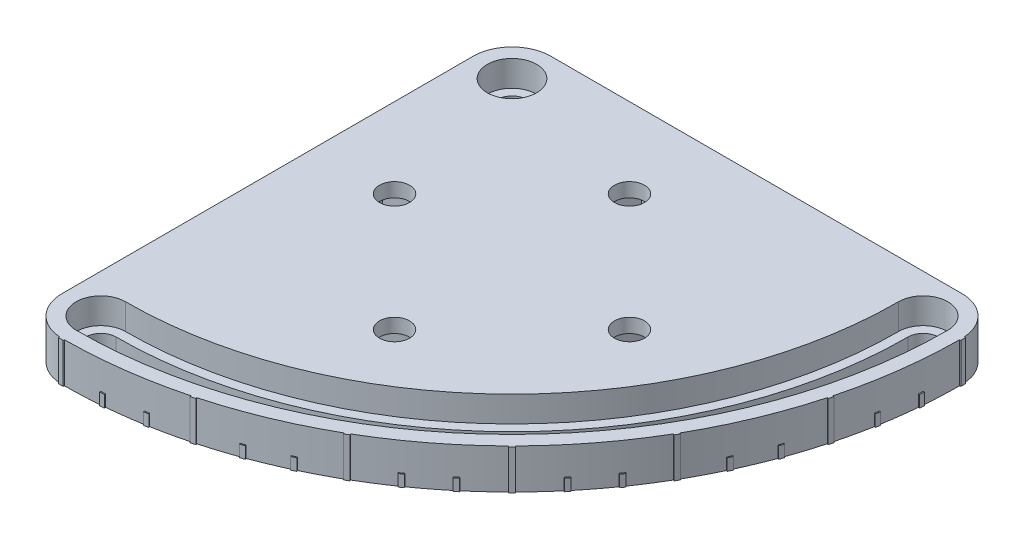
from build123d import *

# Parameters (mm, degrees)
SKETCH_1_R               = 3.2
EXTRUDE_1_DEPTH          = 8.5
EXTRUDE_2_DEPTH          = 8.5
PATTERN_CIRCULAR_1_COUNT = 7
PATTERN_CIRCULAR_1_ANGLE = 90
EXTRUDE_3_DEPTH          = 2.5
PATTERN_CIRCULAR_2_COUNT = 19
PATTERN_CIRCULAR_2_ANGLE = 90
CUT_EXTRUDE_1_DEPTH      = 5.5
CUT_EXTRUDE_2_DEPTH      = 5.5
EXTRUDE_4_DEPTH          = 8.5
SKETCH_10_R              = 3.25
CUT_EXTRUDE_3_DEPTH      = 8.5
SKETCH_11_R              = 5.25
CUT_EXTRUDE_4_DEPTH      = 5.5


with BuildPart() as part:
    # 스케치1 → 보스-돌출1 (new body)
    with BuildSketch(Plane(origin=(0, 0, 0), x_dir=(1, 0, 0), z_dir=(0, 1, 0))):
        with BuildLine():
            Line((-8.25, -87.5), (-8.25, -22.5))
            ThreePointArc((-8.25, -22.5), (-5.833630945, -16.666369055), (0, -14.25))
            ThreePointArc((0, -14.25), (10.076271632, -10.076271632), (14.25, 0))
            ThreePointArc((14.25, 0), (16.666369055, 5.833630945), (22.5, 8.25))
            Line((22.5, 8.25), (87.5, 8.25))
            ThreePointArc((87.5, 8.25), (93.333630945, 5.833630945), (95.75, 0))
            ThreePointArc((95.75, 0), (67.705474299, -67.705474299), (0, -95.75))
            ThreePointArc((0, -95.75), (-5.833630945, -93.333630945), (-8.25, -87.5))
        make_face()
        with Locations((58.75, -33.75)):
            Circle(SKETCH_1_R, mode=Mode.SUBTRACT)
        with Locations((33.75, -58.75)):
            Circle(SKETCH_1_R, mode=Mode.SUBTRACT)
        with Locations((8.75, -33.75)):
            Circle(SKETCH_1_R, mode=Mode.SUBTRACT)
        with Locations((33.75, -8.75)):
            Circle(SKETCH_1_R, mode=Mode.SUBTRACT)
        with BuildLine():
            ThreePointArc((0, -19.25), (-3.25, -22.5), (0, -25.75))
            ThreePointArc((0, -25.75), (18.207999616, -18.207999616), (25.75, 0))
            ThreePointArc((25.75, 0), (22.5, 3.25), (19.25, 0))
            ThreePointArc((19.25, 0), (13.611805538, -13.611805538), (0, -19.25))
        make_face(mode=Mode.SUBTRACT)
        with BuildLine():
            ThreePointArc((0, -84.25), (-3.25, -87.5), (0, -90.75))
            ThreePointArc((0, -90.75), (64.169940393, -64.169940393), (90.75, 0))
            ThreePointArc((90.75, 0), (87.5, 3.25), (84.25, 0))
            ThreePointArc((84.25, 0), (59.573746315, -59.573746315), (0, -84.25))
        make_face(mode=Mode.SUBTRACT)
    extrude(amount=EXTRUDE_1_DEPTH)

    # 스케치2 → 보스-돌출2 (add)
    with BuildSketch(Plane(origin=(0, 8.5, 0), x_dir=(1, 0, 0), z_dir=(0, 1, 0))):
        with BuildLine():
            Line((0.497416564, -94.998697764), (0.502652528, -95.998684056))
            ThreePointArc((0.502652528, -95.998684056), (0, -96), (-0.502652528, -95.998684056))
            Line((-0.502652528, -95.998684056), (-0.497416564, -94.998697764))
            ThreePointArc((-0.497416564, -94.998697764), (0, -95), (0.497416564, -94.998697764))
        make_face()
    extrude_2 = extrude(amount=-EXTRUDE_2_DEPTH)

    # 원형 패턴1: 보스-돌출2 ×7 about axis
    pattern_circular_1_axis = Axis((0, 0, 0), (0, 1, 0))
    for i in range(1, PATTERN_CIRCULAR_1_COUNT):
        add(extrude_2.rotate(pattern_circular_1_axis, i * PATTERN_CIRCULAR_1_ANGLE / (PATTERN_CIRCULAR_1_COUNT - 1)))

    # 스케치6 → 보스-돌출3 (add)
    with BuildSketch(Plane.XZ):
        with BuildLine():
            Line((95.998684056, 0.502652528), (95.49869091, 0.500034546))
            ThreePointArc((95.49869091, 0.500034546), (95.5, 0), (95.49869091, -0.500034546))
            Line((95.49869091, -0.500034546), (95.998684056, -0.502652528))
            ThreePointArc((95.998684056, -0.502652528), (96, 0), (95.998684056, 0.502652528))
        make_face()
    extrude_3 = extrude(amount=-EXTRUDE_3_DEPTH)

    # 원형 패턴2: 보스-돌출3 ×19 about axis
    pattern_circular_2_axis = Axis((0, 8.5, 0), (0, -1, 0))
    for i in range(1, PATTERN_CIRCULAR_2_COUNT):
        add(extrude_3.rotate(pattern_circular_2_axis, i * PATTERN_CIRCULAR_2_ANGLE / (PATTERN_CIRCULAR_2_COUNT - 1)))

    # 스케치7 → 컷-돌출1 (cut)
    with BuildSketch(Plane.XZ):
        Polygon((26.650803984, 56.831298374), (35.668701626, 51.650803984), (40.849196016, 60.668701626), (31.831298374, 65.849196016), align=None)
        Polygon((51.650803984, 35.668701626), (56.831298374, 26.650803984), (65.849196016, 31.831298374), (60.668701626, 40.849196016), align=None)
        Polygon((30.021419355, 2.411412904), (40.088587096, 5.021419355), (37.478580645, 15.088587096), (27.411412904, 12.478580645), align=None)
        Polygon((2.411412904, 30.021419355), (12.478580645, 27.411412904), (15.088587096, 37.478580645), (5.021419355, 40.088587096), align=None)
    extrude(amount=-CUT_EXTRUDE_1_DEPTH, mode=Mode.SUBTRACT)

    # 스케치8 → 컷-돌출2 (cut)
    with BuildSketch(Plane(origin=(0, 8.5, 0), x_dir=(1, 0, 0), z_dir=(0, 1, 0))):
        with BuildLine():
            ThreePointArc((27.75, 0), (22.5, 5.25), (17.25, 0))
            ThreePointArc((17.25, 0), (12.197591975, -12.197591975), (0, -17.25))
            ThreePointArc((0, -17.25), (-5.25, -22.5), (0, -27.75))
            ThreePointArc((0, -27.75), (19.622213178, -19.622213178), (27.75, 0))
        make_face()
        with BuildLine():
            ThreePointArc((92.75, 0), (87.5, 5.25), (82.25, 0))
            ThreePointArc((82.25, 0), (58.159532753, -58.159532753), (0, -82.25))
            ThreePointArc((0, -82.25), (-5.25, -87.5), (0, -92.75))
            ThreePointArc((0, -92.75), (65.584153955, -65.584153955), (92.75, 0))
        make_face()
    extrude(amount=-CUT_EXTRUDE_2_DEPTH, mode=Mode.SUBTRACT)

    # 스케치9 → 보스-돌출4 (add)
    with BuildSketch(Plane(origin=(0, 8.5, 0), x_dir=(1, 0, 0), z_dir=(0, 1, 0))):
        with BuildLine():
            Line((-8.25, -22.5), (-8.25, 0))
            ThreePointArc((-8.25, 0), (-5.833630945, 5.833630945), (0, 8.25))
            Line((0, 8.25), (22.5, 8.25))
            Line((22.5, 8.25), (27.75, 8.25))
            Line((27.75, 8.25), (27.75, 0))
            ThreePointArc((27.75, 0), (19.622213178, -19.622213178), (0, -27.75))
            Line((0, -27.75), (-8.25, -27.75))
            Line((-8.25, -27.75), (-8.25, -22.5))
        make_face()
    extrude(amount=-EXTRUDE_4_DEPTH)

    # 스케치10 → 컷-돌출3 (cut)
    with BuildSketch(Plane(origin=(0, 8.5, 0), x_dir=(1, 0, 0), z_dir=(0, 1, 0))):
        Circle(SKETCH_10_R)
    extrude(amount=-CUT_EXTRUDE_3_DEPTH, mode=Mode.SUBTRACT)

    # 스케치11 → 컷-돌출4 (cut)
    with BuildSketch(Plane(origin=(0, 8.5, 0), x_dir=(1, 0, 0), z_dir=(0, 1, 0))):
        Circle(SKETCH_11_R)
    extrude(amount=-CUT_EXTRUDE_4_DEPTH, mode=Mode.SUBTRACT)


solid = part.part
